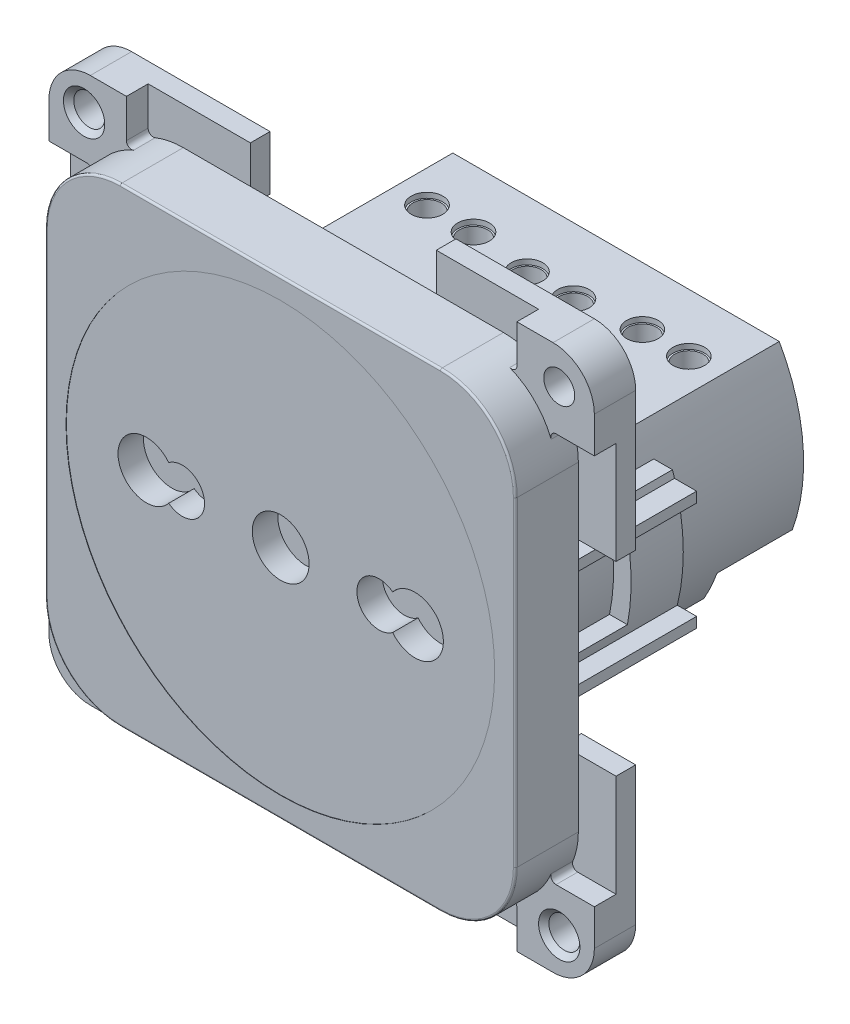
from build123d import *
from build123d.topology import SkipClean

# Parameters (mm, degrees)
SKETCH1_W                = 45.5
SKETCH1_H                = 45.5
BOSS_EXTRUDE1_DEPTH      = 3.05
FILLET2_R                = 7.25
CUT_EXTRUDE2_DEPTH       = 1.75
CUT_EXTRUDE3_REACH       = 8.1
SKETCH5_R                = 2.75
SKETCH6_R                = 20.75
CUT_EXTRUDE4_DEPTH       = 0.035
BOSS_EXTRUDE2_DEPTH      = 1.9
BOSS_EXTRUDE3_DEPTH      = 2.1
FILLET6_R                = 4
CIRPATTERN1_COUNT        = 4
FILLET6_OF_CIRPATTERN1_R = 4
BOSS_EXTRUDE4_DEPTH      = 14.8
CUT_EXTRUDE5_DEPTH       = 13.05
CUT_EXTRUDE6_START       = -3.381401
SKETCH14_W               = 8
SKETCH14_H               = 7.5
CUT_EXTRUDE6_DEPTH       = 2.091401
SKETCH22_R               = 18.16
CUT_EXTRUDE12_DEPTH      = 1.85
BOSS_EXTRUDE5_DEPTH      = 16.15
CHAMFER1_SIZE            = 1
BOSS_EXTRUDE6_DEPTH      = 13.85
CUT_EXTRUDE7_DEPTH       = 7.29
SKETCH18_R               = 2.625
CUT_EXTRUDE8_DEPTH       = 2.5
CUT_EXTRUDE9_DEPTH       = 0.5
SKETCH20_R               = 1.375
CUT_EXTRUDE10_DEPTH      = 6
CHAMFER2_SIZE            = 0.5
FILLET7_R                = 0.5
FILLET8_R                = 0.1875
SKETCH21_R               = 1.53125
CUT_EXTRUDE11_DEPTH      = 0.5
CUT_EXTRUDE13_DEPTH      = 1.85


with BuildPart() as part:
    # Sketch1 → Boss-Extrude1 (new body, symmetric)
    with BuildSketch(Plane.XY):
        Rectangle(SKETCH1_W, SKETCH1_H)
    extrude(amount=BOSS_EXTRUDE1_DEPTH, both=True)

    # Fillet2
    fillet2_edges = [part.edges().sort_by_distance(p)[0] for p in [
        (22.75, -22.75, 0),
        (-22.75, -22.75, 0),
        (-22.75, 22.75, 0),
        (22.75, 22.75, 0),
    ]]
    fillet(fillet2_edges, radius=FILLET2_R)

    # Sketch4 → Cut-Extrude2 (cut)
    with BuildSketch(Plane(origin=(0, 0, -3.05), x_dir=(-1, 0, 0), z_dir=(0, 0, -1))):
        with BuildLine():
            Line((-15.5, 21.15), (15.5, 21.15))
            ThreePointArc((15.5, 21.15), (19.495153314, 19.495153314), (21.15, 15.5))
            Line((21.15, 15.5), (21.15, -15.5))
            ThreePointArc((21.15, -15.5), (19.495153314, -19.495153314), (15.5, -21.15))
            Line((15.5, -21.15), (-15.5, -21.15))
            ThreePointArc((-15.5, -21.15), (-19.495153314, -19.495153314), (-21.15, -15.5))
            Line((-21.15, -15.5), (-21.15, 15.5))
            ThreePointArc((-21.15, 15.5), (-19.495153314, 19.495153314), (-15.5, 21.15))
        make_face()
    extrude(amount=-CUT_EXTRUDE2_DEPTH, mode=Mode.SUBTRACT)

    # Sketch5 → Cut-Extrude3 (cut, up to next)
    with BuildSketch(Plane.XY.offset(3.05), mode=Mode.PRIVATE) as cut_extrude3_sk1:
        Circle(SKETCH5_R)
    cut_extrude3_tool1 = extrude(cut_extrude3_sk1.sketch, amount=-CUT_EXTRUDE3_REACH, mode=Mode.PRIVATE) & part.part
    add(cut_extrude3_tool1.solids().sort_by_distance((0, 0, 3.05))[0], mode=Mode.SUBTRACT)
    # Sketch5 → Cut-Extrude3 (cut, up to next)
    with BuildSketch(Plane.XY.offset(3.05), mode=Mode.PRIVATE) as cut_extrude3_sk2:
        with BuildLine():
            ThreePointArc((-10.839478417, 1.701366066), (-15.75, 0), (-10.839478417, -1.701366066))
            ThreePointArc((-10.839478417, -1.701366066), (-7.375, 0), (-10.839478417, 1.701366066))
        make_face()
    cut_extrude3_tool2 = extrude(cut_extrude3_sk2.sketch, amount=-CUT_EXTRUDE3_REACH, mode=Mode.PRIVATE) & part.part
    add(cut_extrude3_tool2.solids().sort_by_distance((-11.752563, 0, 3.05))[0], mode=Mode.SUBTRACT)
    # Sketch5 → Cut-Extrude3 (cut, up to next)
    with BuildSketch(Plane.XY.offset(3.05), mode=Mode.PRIVATE) as cut_extrude3_sk3:
        with BuildLine():
            ThreePointArc((10.839478417, -1.701366066), (15.75, 0), (10.839478417, 1.701366066))
            ThreePointArc((10.839478417, 1.701366066), (7.375, 0), (10.839478417, -1.701366066))
        make_face()
    cut_extrude3_tool3 = extrude(cut_extrude3_sk3.sketch, amount=-CUT_EXTRUDE3_REACH, mode=Mode.PRIVATE) & part.part
    add(cut_extrude3_tool3.solids().sort_by_distance((11.752563, 0, 3.05))[0], mode=Mode.SUBTRACT)

    # Sketch6 → Cut-Extrude4 (cut)
    with BuildSketch(Plane.XY.offset(3.05)):
        Circle(SKETCH6_R)
    extrude(amount=-CUT_EXTRUDE4_DEPTH, mode=Mode.SUBTRACT)

    # Sketch7 → Boss-Extrude2 (add)
    with BuildSketch(Plane(origin=(0, 0, -3.05), x_dir=(-1, 0, 0), z_dir=(0, 0, -1))):
        with BuildLine():
            Line((9, 21.15), (9, 26.4))
            Line((9, 26.4), (26.4, 26.4))
            Line((26.4, 26.4), (26.4, 9))
            Line((26.4, 9), (21.15, 9))
            Line((21.15, 9), (21.15, 15.5))
            ThreePointArc((21.15, 15.5), (19.495153314, 19.495153314), (15.5, 21.15))
            Line((15.5, 21.15), (9, 21.15))
        make_face()
    boss_extrude2 = extrude(amount=BOSS_EXTRUDE2_DEPTH)

    # Sketch8 → Boss-Extrude3 (add)
    with BuildSketch(Plane.XY.offset(-3.05)):
        with BuildLine():
            Line((-26.4, 26.4), (-18.9, 26.4))
            Line((-18.9, 26.4), (-18.9, 21.903319452))
            ThreePointArc((-18.9, 21.903319452), (-20.626524164, 20.626524164), (-21.903319452, 18.9))
            Line((-21.903319452, 18.9), (-26.4, 18.9))
            Line((-26.4, 18.9), (-26.4, 26.4))
        make_face()
    boss_extrude3 = extrude(amount=BOSS_EXTRUDE3_DEPTH)

    # Fillet6
    fillet6_edges = [part.edges().sort_by_distance(p)[0] for p in [
        (-26.4, 26.4, -2.95),
    ]]
    fillet(fillet6_edges, radius=FILLET6_R)

    # Sketch10 → 3.0 _3_ Diameter Hole1 (revolve, cut)
    with BuildSketch(Plane(origin=(-23, 23, -0.95), x_dir=(0, -1, 0), z_dir=(1, 0, 0))):
        Polygon((0, 0), (0, 13.601290929), (1.5, 12.7), (1.5, 0), align=None)
    f_3_0_3_diameter_hole1 = revolve(axis=Axis((-23, 23, 5.4), (0, 0, -1)), mode=Mode.SUBTRACT)

    # CirPattern1: Boss-Extrude2, Boss-Extrude3, 3.0 _3_ Diameter Hole1 ×4 about axis
    cirpattern1_axis = Axis((0, 0, 0), (0, 0, 1))
    add([boss_extrude2.rotate(cirpattern1_axis, i * 360 / CIRPATTERN1_COUNT) for i in range(1, CIRPATTERN1_COUNT)])
    add([boss_extrude3.rotate(cirpattern1_axis, i * 360 / CIRPATTERN1_COUNT) for i in range(1, CIRPATTERN1_COUNT)])
    add([f_3_0_3_diameter_hole1.rotate(cirpattern1_axis, i * 360 / CIRPATTERN1_COUNT) for i in range(1, CIRPATTERN1_COUNT)], mode=Mode.SUBTRACT)

    # Fillet6 of CirPattern1
    fillet6_of_cirpattern1_edges = [part.edges().sort_by_distance(p)[0] for p in [
        (-26.4, -26.4, -2.95),
        (26.4, -26.4, -2.95),
        (26.4, 26.4, -2.95),
    ]]
    fillet(fillet6_of_cirpattern1_edges, radius=FILLET6_OF_CIRPATTERN1_R)

    # Sketch12 → Boss-Extrude4 (add)
    with BuildSketch(Plane(origin=(0, 0, -1.3), x_dir=(-1, 0, 0), z_dir=(0, 0, -1))):
        with BuildLine():
            Line((17.004263436, 6.375), (21.15, 6.375))
            Line((21.15, 6.375), (21.15, -6.375))
            Line((21.15, -6.375), (17.004263436, -6.375))
            ThreePointArc((17.004263436, -6.375), (18.16, 0), (17.004263436, 6.375))
        make_face()
    boss_extrude4 = extrude(amount=BOSS_EXTRUDE4_DEPTH)

    # Sketch13 → Cut-Extrude5 (cut)
    with BuildSketch(Plane(origin=(0, 0, -16.1), x_dir=(-1, 0, 0), z_dir=(0, 0, -1))):
        with BuildLine():
            Line((22.75, 6.375), (18.809013132, 6.375))
            ThreePointArc((18.809013132, 6.375), (18.911786154, 6.063327839), (19.009395046, 5.75))
            Line((19.009395046, 5.75), (21.15, 5.75))
            Line((21.15, 5.75), (21.15, 4.75))
            Line((21.15, 4.75), (19.283596656, 4.75))
            ThreePointArc((19.283596656, 4.75), (19.86, 0), (19.283596656, -4.75))
            Line((19.283596656, -4.75), (21.15, -4.75))
            Line((21.15, -4.75), (21.15, -5.75))
            Line((21.15, -5.75), (19.009395046, -5.75))
            ThreePointArc((19.009395046, -5.75), (18.911786154, -6.063327839), (18.809013132, -6.375))
            Line((18.809013132, -6.375), (22.75, -6.375))
            Line((22.75, -6.375), (22.75, 6.375))
        make_face()
    cut_extrude5 = extrude(amount=-CUT_EXTRUDE5_DEPTH, mode=Mode.SUBTRACT)

    # Sketch14 → Cut-Extrude6 (cut)
    with BuildSketch(Plane.ZY.offset(21.15).offset(CUT_EXTRUDE6_START)):
        with Locations((-7.05, 0)):
            Rectangle(SKETCH14_W, SKETCH14_H)
    cut_extrude6 = extrude(amount=CUT_EXTRUDE6_DEPTH, mode=Mode.SUBTRACT)

    # Mirror1: Boss-Extrude4, Cut-Extrude5, Cut-Extrude6 across plane
    add(boss_extrude4.mirror(Plane(origin=(0, 0, 0), x_dir=(0, 0, 1), z_dir=(1, 0, 0))))
    add(cut_extrude5.mirror(Plane(origin=(0, 0, 0), x_dir=(0, 0, 1), z_dir=(1, 0, 0))), mode=Mode.SUBTRACT)
    add(cut_extrude6.mirror(Plane(origin=(0, 0, 0), x_dir=(0, 0, 1), z_dir=(1, 0, 0))), mode=Mode.SUBTRACT)

    # Sketch22 → Cut-Extrude12 (cut)
    with BuildSketch(Plane(origin=(0, 0, -1.3), x_dir=(-1, 0, 0), z_dir=(0, 0, -1))):
        with Locations(Location((0, 0, 0), (0, 0, 200.551322128))):  # turned: the seam where the file's is
            Circle(SKETCH22_R)
    extrude(amount=-CUT_EXTRUDE12_DEPTH, mode=Mode.SUBTRACT)

    # Sketch15 → Boss-Extrude5 (add)
    with BuildSketch(Plane(origin=(0, 0, 0.55), x_dir=(-1, 0, 0), z_dir=(0, 0, -1))):
        with BuildLine():
            Line((-15.191546992, -9.95), (15.191546992, -9.95))
            ThreePointArc((15.191546992, -9.95), (18.16, 0), (15.191546992, 9.95))
            Line((15.191546992, 9.95), (-15.191546992, 9.95))
            ThreePointArc((-15.191546992, 9.95), (-18.16, 0), (-15.191546992, -9.95))
        make_face()
    extrude(amount=BOSS_EXTRUDE5_DEPTH)

    # Chamfer1
    chamfer1_edges = [part.edges().sort_by_distance(p)[0] for p in [
        (0, -9.95, -15.6),
        (0, 9.95, -15.6),
    ]]
    chamfer(chamfer1_edges, length=CHAMFER1_SIZE)

    # Sketch16 → Boss-Extrude6 (add)
    with BuildSketch(Plane(origin=(0, 0, -15.6), x_dir=(-1, 0, 0), z_dir=(0, 0, -1))):
        with BuildLine():
            Line((15.801363865, 8.95), (-15.801363865, 8.95))
            ThreePointArc((-15.801363865, 8.95), (-16.453265691, 7.686068442), (-17.004263436, 6.375))
            ThreePointArc((-17.004263436, 6.375), (-18.16, 0), (-17.004263436, -6.375))
            ThreePointArc((-17.004263436, -6.375), (-16.453265691, -7.686068442), (-15.801363865, -8.95))
            Line((-15.801363865, -8.95), (15.801363865, -8.95))
            ThreePointArc((15.801363865, -8.95), (16.453265691, -7.686068442), (17.004263436, -6.375))
            ThreePointArc((17.004263436, -6.375), (18.16, 0), (17.004263436, 6.375))
            ThreePointArc((17.004263436, 6.375), (16.453265691, 7.686068442), (15.801363865, 8.95))
        make_face()
    extrude(amount=BOSS_EXTRUDE6_DEPTH)

    # Sketch17 → Cut-Extrude7 (cut)
    with BuildSketch(Plane(origin=(0, 0, -29.45), x_dir=(-1, 0, 0), z_dir=(0, 0, -1))):
        with BuildLine():
            Line((-15.801363865, -8.95), (-5.375, -8.95))
            Line((-5.375, -8.95), (-5.375, -6.2))
            Line((-5.375, -6.2), (-17.068848819, -6.2))
            ThreePointArc((-17.068848819, -6.2), (-16.492523927, -7.601463973), (-15.801363865, -8.95))
        make_face()
        with BuildLine():
            Line((5.375, -8.95), (5.375, -6.2))
            Line((5.375, -6.2), (17.068848819, -6.2))
            ThreePointArc((17.068848819, -6.2), (16.492523927, -7.601463973), (15.801363865, -8.95))
            Line((15.801363865, -8.95), (5.375, -8.95))
        make_face()
    extrude(amount=-CUT_EXTRUDE7_DEPTH, mode=Mode.SUBTRACT)

    # Sketch18 → Cut-Extrude8 (cut)
    with BuildSketch(Plane(origin=(0, 0, -29.45), x_dir=(-1, 0, 0), z_dir=(0, 0, -1))):
        with Locations((0, -1.925)):
            Circle(SKETCH18_R)
        with Locations((-10.2, -1.275)):
            Circle(SKETCH18_R)
        with Locations((10.2, -1.275)):
            Circle(SKETCH18_R)
    extrude(amount=-CUT_EXTRUDE8_DEPTH, mode=Mode.SUBTRACT)

    # Sketch19 → Cut-Extrude9 (cut)
    with BuildSketch(Plane(origin=(0, 0, -26.95), x_dir=(-1, 0, 0), z_dir=(0, 0, -1))):
        with BuildLine():
            Line((0.25, -1.425), (0.25, -0.8))
            Line((0.25, -0.8), (-0.25, -0.8))
            Line((-0.25, -0.8), (-0.25, -1.425))
            Line((-0.25, -1.425), (-2.576941016, -1.425))
            ThreePointArc((-2.576941016, -1.425), (-2.625, -1.925), (-2.576941016, -2.425))
            Line((-2.576941016, -2.425), (-0.25, -2.425))
            Line((-0.25, -2.425), (-0.25, -3.05))
            Line((-0.25, -3.05), (0.25, -3.05))
            Line((0.25, -3.05), (0.25, -2.425))
            Line((0.25, -2.425), (2.576941016, -2.425))
            ThreePointArc((2.576941016, -2.425), (2.625, -1.925), (2.576941016, -1.425))
            Line((2.576941016, -1.425), (0.25, -1.425))
        make_face()
        with BuildLine():
            Line((7.623058984, -1.775), (9.95, -1.775))
            Line((9.95, -1.775), (9.95, -2.4))
            Line((9.95, -2.4), (10.45, -2.4))
            Line((10.45, -2.4), (10.45, -1.775))
            Line((10.45, -1.775), (12.776941016, -1.775))
            ThreePointArc((12.776941016, -1.775), (12.825, -1.275), (12.776941016, -0.775))
            Line((12.776941016, -0.775), (10.45, -0.775))
            Line((10.45, -0.775), (10.45, -0.15))
            Line((10.45, -0.15), (9.95, -0.15))
            Line((9.95, -0.15), (9.95, -0.775))
            Line((9.95, -0.775), (7.623058984, -0.775))
            ThreePointArc((7.623058984, -0.775), (7.575, -1.275), (7.623058984, -1.775))
        make_face()
        with BuildLine():
            Line((-7.623058984, -0.775), (-9.95, -0.775))
            Line((-9.95, -0.775), (-9.95, -0.15))
            Line((-9.95, -0.15), (-10.45, -0.15))
            Line((-10.45, -0.15), (-10.45, -0.775))
            Line((-10.45, -0.775), (-12.776941016, -0.775))
            ThreePointArc((-12.776941016, -0.775), (-12.825, -1.275), (-12.776941016, -1.775))
            Line((-12.776941016, -1.775), (-10.45, -1.775))
            Line((-10.45, -1.775), (-10.45, -2.4))
            Line((-10.45, -2.4), (-9.95, -2.4))
            Line((-9.95, -2.4), (-9.95, -1.775))
            Line((-9.95, -1.775), (-7.623058984, -1.775))
            ThreePointArc((-7.623058984, -1.775), (-7.575, -1.275), (-7.623058984, -0.775))
        make_face()
    extrude(amount=-CUT_EXTRUDE9_DEPTH, mode=Mode.SUBTRACT)

    # Sketch20 → Cut-Extrude10 (cut)
    with BuildSketch(Plane(origin=(0, 8.95, 0), x_dir=(1, 0, 0), z_dir=(0, 1, 0))):
        with Locations(Location((-12.675, 23.825, 0), (0, 0, 180))):  # turned: the seam where the file's is
            Circle(SKETCH20_R)
        with Locations(Location((-8.175, 23.825, 0), (0, 0, 180))):  # turned: the seam where the file's is
            Circle(SKETCH20_R)
        with Locations(Location((8.175, 23.825, 0), (0, 0, 180))):  # turned: the seam where the file's is
            Circle(SKETCH20_R)
        with Locations(Location((12.675, 23.825, 0), (0, 0, 180))):  # turned: the seam where the file's is
            Circle(SKETCH20_R)
        with Locations(Location((-2.25, 23.075, 0), (0, 0, 180))):  # turned: the seam where the file's is
            Circle(SKETCH20_R)
        with Locations(Location((2.25, 23.075, 0), (0, 0, 180))):  # turned: the seam where the file's is
            Circle(SKETCH20_R)
    extrude(amount=-CUT_EXTRUDE10_DEPTH, mode=Mode.SUBTRACT)

    # Chamfer2
    chamfer2_edges = [part.edges().sort_by_distance(p)[0] for p in [
        (-23, 24.5, -0.95),
        (23, -24.5, -0.95),
    ]]
    chamfer(chamfer2_edges, length=CHAMFER2_SIZE)

    # Fillet7
    fillet7_edges = [part.edges().sort_by_distance(p)[0] for p in [
        (-21.903319452, 18.9, -2),
        (-18.9, 21.903319452, -2),
        (-18.9, -21.903319452, -2),
        (-21.903319452, -18.9, -2),
        (21.903319452, -18.9, -2),
        (18.9, -21.903319452, -2),
        (18.9, 21.903319452, -2),
        (21.903319452, 18.9, -2),
    ]]
    fillet(fillet7_edges, radius=FILLET7_R)

    # Fillet8
    fillet8_edges = [part.edges().sort_by_distance(p)[0] for p in [
        (22.75, 0, 3.05),
        (0, -22.75, 3.05),
        (0, 22.75, 3.05),
        (-22.75, 0, 3.05),
        (20.626524164, 20.626524164, 3.05),
        (-20.626524164, 20.626524164, 3.05),
        (-20.626524164, -20.626524164, 3.05),
        (20.626524164, -20.626524164, 3.05),
    ]]
    fillet(fillet8_edges, radius=FILLET8_R)

    # Sketch21 → Cut-Extrude11 (cut)
    with BuildSketch(Plane(origin=(0, 8.95, 0), x_dir=(1, 0, 0), z_dir=(0, 1, 0))):
        with Locations(Location((2.25, 23.075, 0), (0, 0, 180))):  # turned: the seam where the file's is
            Circle(SKETCH21_R)
        with Locations(Location((8.175, 23.825, 0), (0, 0, 180))):  # turned: the seam where the file's is
            Circle(SKETCH21_R)
        with Locations(Location((12.675, 23.825, 0), (0, 0, 180))):  # turned: the seam where the file's is
            Circle(SKETCH21_R)
        with Locations(Location((-12.675, 23.825, 0), (0, 0, 180))):  # turned: the seam where the file's is
            Circle(SKETCH21_R)
        with Locations(Location((-8.175, 23.825, 0), (0, 0, 180))):  # turned: the seam where the file's is
            Circle(SKETCH21_R)
        with Locations(Location((-2.25, 23.075, 0), (0, 0, 180))):  # turned: the seam where the file's is
            Circle(SKETCH21_R)
    extrude(amount=-CUT_EXTRUDE11_DEPTH, mode=Mode.SUBTRACT)

    # Sketch23 → Cut-Extrude13 (cut)
    with SkipClean():  # keep this step's faces unmerged: merging them makes the solid invalid here
        with BuildSketch(Plane(origin=(0, 0, 0.55), x_dir=(-1, 0, 0), z_dir=(0, 0, -1))):
            with BuildLine():
                Line((-18.956776493, 6.375), (-17.004263436, 6.375))
                ThreePointArc((-17.004263436, 6.375), (0, 18.16), (17.004263436, 6.375))
                Line((17.004263436, 6.375), (18.956776493, 6.375))
                ThreePointArc((18.956776493, 6.375), (0, 20), (-18.956776493, 6.375))
            make_face()
            with BuildLine():
                Line((-17.004263436, -6.375), (-18.956776493, -6.375))
                ThreePointArc((-18.956776493, -6.375), (0, -20), (18.956776493, -6.375))
                Line((18.956776493, -6.375), (17.004263436, -6.375))
                ThreePointArc((17.004263436, -6.375), (0, -18.16), (-17.004263436, -6.375))
            make_face()
        extrude(amount=CUT_EXTRUDE13_DEPTH, mode=Mode.SUBTRACT)


solid = part.part
